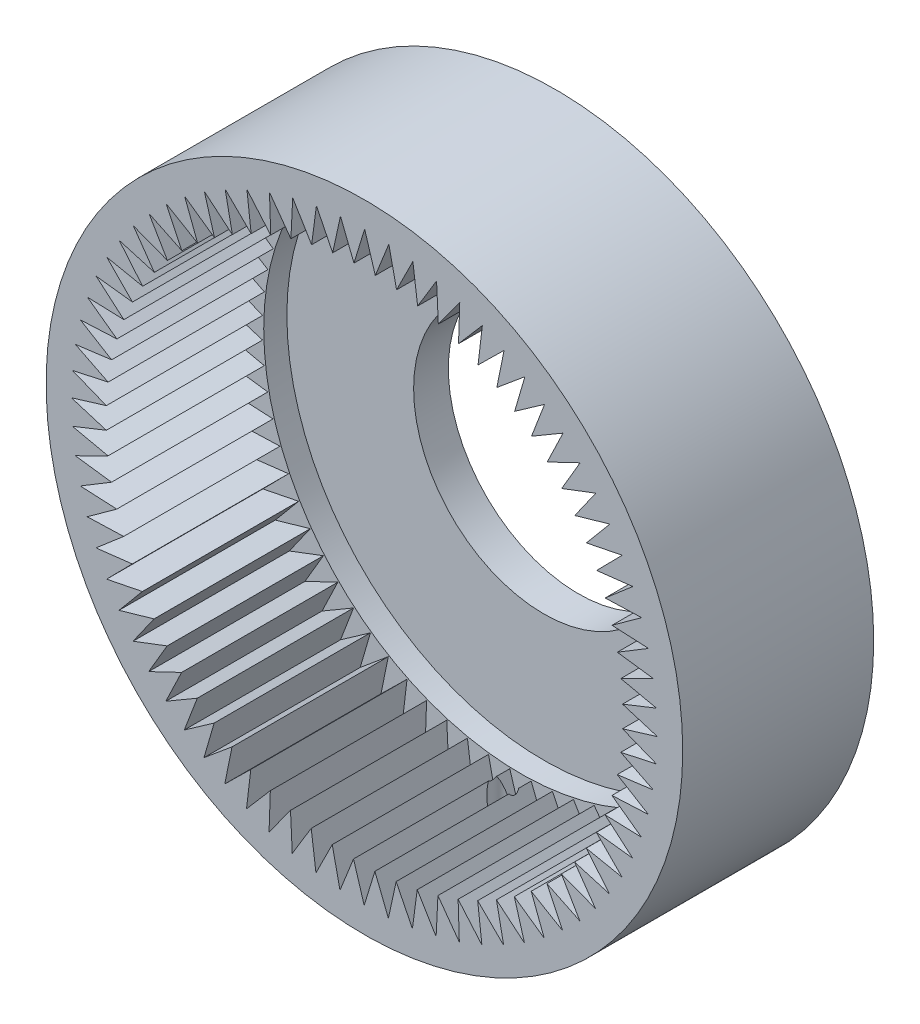
from build123d import *

# Parameters (mm, degrees)
SKETCH1_R           = 27.5
BOSS_EXTRUDE1_DEPTH = 6
BOSS_EXTRUDE2_START = 6
SKETCH2_R           = 27.5
BOSS_EXTRUDE2_DEPTH = 4.5
BOSS_EXTRUDE3_START = 10.5
SKETCH3_R           = 27.5
BOSS_EXTRUDE3_DEPTH = 6
CUT_EXTRUDE1_DEPTH  = 13.5
SKETCH10_R          = 23
BOSS_EXTRUDE4_DEPTH = 2
CUT_EXTRUDE7_START  = 16.5
SKETCH6_R           = 11.25
CUT_EXTRUDE7_DEPTH  = 19.5
CUT_EXTRUDE10_START = 3
SKETCH11_R          = 22.2
CUT_EXTRUDE10_DEPTH = 2
SKETCH12_R          = 1
CUT_EXTRUDE11_DEPTH = 28.5
SKETCH13_R          = 3.5
CUT_EXTRUDE12_DEPTH = 3


with BuildPart() as part:
    # Sketch1 → Boss-Extrude1 (new body)
    with BuildSketch(Plane.XY):
        Circle(SKETCH1_R)
    extrude(amount=BOSS_EXTRUDE1_DEPTH)

    # Sketch2 → Boss-Extrude2 (add)
    with BuildSketch(Plane.XY.offset(BOSS_EXTRUDE2_START)):
        Circle(SKETCH2_R)
    extrude(amount=BOSS_EXTRUDE2_DEPTH)

    # Sketch3 → Boss-Extrude3 (add)
    with BuildSketch(Plane.XY.offset(BOSS_EXTRUDE3_START)):
        Circle(SKETCH3_R)
    extrude(amount=BOSS_EXTRUDE3_DEPTH)

    # Sketch4 → Cut-Extrude1 (cut)
    with BuildSketch(Plane.XY.offset(16.5)):
        Polygon((8.200315972, -23.949003355), (8.095646912, -20.796423541), (10.150000757, -23.190028641), (9.785351218, -20.056859988), (12.030350745, -22.272642516), (11.408211652, -19.180287743), (13.828521239, -21.20311166), (12.953142433, -18.172694685), (15.532228911, -19.988742051), (14.409590118, -17.040963696), (17.12983571, -18.637829065), (15.76760569, -15.792825644), (18.610428362, -17.159600809), (17.017912527, -14.43680658), (19.963892917, -15.564155079), (18.151969766, -12.982169489), (21.18098384, -13.862390389), (19.162030646, -11.438851016), (22.253387167, -12.065931515), (20.041195426, -9.817393592), (23.173777294, -10.187050095), (20.78345852, -8.128873414), (23.935867025, -8.238580793), (21.383749518, -6.384824789), (24.534450513, -6.233833631), (21.837967824, -4.597161336), (24.965438827, -4.186503063), (22.143010666, -2.77809461), (25.225887879, -2.110574435), (22.296794293, -0.940050681), (25.314018538, -0.020228443), (22.298268206, 0.904414747), (25.229228782, 2.070255729), (22.147422337, 2.742702106), (24.972097812, 4.146597956), (21.845287117, 4.562254028), (24.544382092, 6.194614714), (21.393926434, 6.350641129), (23.949003355, 8.200315972), (20.796423541, 8.095646912), (23.190028641, 10.150000757), (20.056859988, 9.785351218), (22.272642516, 12.030350745), (19.180287743, 11.408211652), (21.20311166, 13.828521239), (18.172694685, 12.953142433), (19.988742051, 15.532228911), (17.040963696, 14.409590118), (18.637829065, 17.12983571), (15.792825644, 15.76760569), (17.159600809, 18.610428362), (14.43680658, 17.017912527), (15.564155079, 19.963892917), (12.982169489, 18.151969766), (13.862390389, 21.18098384), (11.438851016, 19.162030646), (12.065931515, 22.253387167), (9.817393592, 20.041195426), (10.187050095, 23.173777294), (8.128873414, 20.78345852), (8.238580793, 23.935867025), (6.384824789, 21.383749518), (6.233833631, 24.534450513), (4.597161336, 21.837967824), (4.186503063, 24.965438827), (2.77809461, 22.143010666), (2.110574435, 25.225887879), (0.940050681, 22.296794293), (0.020228443, 25.314018538), (-0.904414747, 22.298268206), (-2.070255729, 25.229228782), (-2.742702106, 22.147422337), (-4.146597956, 24.972097812), (-4.562254028, 21.845287117), (-6.194614714, 24.544382092), (-6.350641129, 21.393926434), (-8.200315972, 23.949003355), (-8.095646912, 20.796423541), (-10.150000757, 23.190028641), (-9.785351218, 20.056859988), (-12.030350745, 22.272642516), (-11.408211652, 19.180287743), (-13.828521239, 21.20311166), (-12.953142433, 18.172694685), (-15.532228911, 19.988742051), (-14.409590118, 17.040963696), (-17.12983571, 18.637829065), (-15.76760569, 15.792825644), (-18.610428362, 17.159600809), (-17.017912527, 14.43680658), (-19.963892917, 15.564155079), (-18.151969766, 12.982169489), (-21.18098384, 13.862390389), (-19.162030646, 11.438851016), (-22.253387167, 12.065931515), (-20.041195426, 9.817393592), (-23.173777294, 10.187050095), (-20.78345852, 8.128873414), (-23.935867025, 8.238580793), (-21.383749518, 6.384824789), (-24.534450513, 6.233833631), (-21.837967824, 4.597161336), (-24.965438827, 4.186503063), (-22.143010666, 2.77809461), (-25.225887879, 2.110574435), (-22.296794293, 0.940050681), (-25.314018538, 0.020228443), (-22.298268206, -0.904414747), (-25.229228782, -2.070255729), (-22.147422337, -2.742702106), (-24.972097812, -4.146597956), (-21.845287117, -4.562254028), (-24.544382092, -6.194614714), (-21.393926434, -6.350641129), (-23.949003355, -8.200315972), (-20.796423541, -8.095646912), (-23.190028641, -10.150000757), (-20.056859988, -9.785351218), (-22.272642516, -12.030350745), (-19.180287743, -11.408211652), (-21.20311166, -13.828521239), (-18.172694685, -12.953142433), (-19.988742051, -15.532228911), (-17.040963696, -14.409590118), (-18.637829065, -17.12983571), (-15.792825644, -15.76760569), (-17.159600809, -18.610428362), (-14.43680658, -17.017912527), (-15.564155079, -19.963892917), (-12.982169489, -18.151969766), (-13.862390389, -21.18098384), (-11.438851016, -19.162030646), (-12.065931515, -22.253387167), (-9.817393592, -20.041195426), (-10.187050095, -23.173777294), (-8.128873414, -20.78345852), (-8.238580793, -23.935867025), (-6.384824789, -21.383749518), (-6.233833631, -24.534450513), (-4.597161336, -21.837967824), (-4.186503063, -24.965438827), (-2.77809461, -22.143010666), (-2.110574435, -25.225887879), (-0.940050681, -22.296794293), (-0.020228443, -25.314018538), (0.904414747, -22.298268206), (2.070255729, -25.229228782), (2.742702106, -22.147422337), (4.146597956, -24.972097812), (4.562254028, -21.845287117), (6.194614714, -24.544382092), (6.350641129, -21.393926434), align=None)
    extrude(amount=-CUT_EXTRUDE1_DEPTH, mode=Mode.SUBTRACT)

    # Sketch10 → Boss-Extrude4 (add)
    with BuildSketch(Plane.XY):
        Circle(SKETCH10_R)
    extrude(amount=-BOSS_EXTRUDE4_DEPTH)

    # Sketch6 → Cut-Extrude7 (cut, through all)
    with BuildSketch(Plane.XY.offset(CUT_EXTRUDE7_START)):
        Circle(SKETCH6_R)
    extrude(amount=-CUT_EXTRUDE7_DEPTH, mode=Mode.SUBTRACT)

    # Sketch11 → Cut-Extrude10 (cut)
    with BuildSketch(Plane.XY.offset(CUT_EXTRUDE10_START)):
        Circle(SKETCH11_R)
    extrude(amount=-CUT_EXTRUDE10_DEPTH, mode=Mode.SUBTRACT)

    # Sketch12 → Cut-Extrude11 (cut, through all)
    with BuildSketch(Plane(origin=(0, 0, 0), x_dir=(1, 0, 0), z_dir=(0, 1, 0))):
        with Locations((0, -4.5)):
            Circle(SKETCH12_R)
    extrude(amount=-CUT_EXTRUDE11_DEPTH, mode=Mode.SUBTRACT)

    # Sketch13 → Cut-Extrude12 (cut, through all)
    with BuildSketch(Plane.XY):
        with Locations((0, -16.58)):
            Circle(SKETCH13_R)
    extrude(amount=-CUT_EXTRUDE12_DEPTH, mode=Mode.SUBTRACT)


solid = part.part
